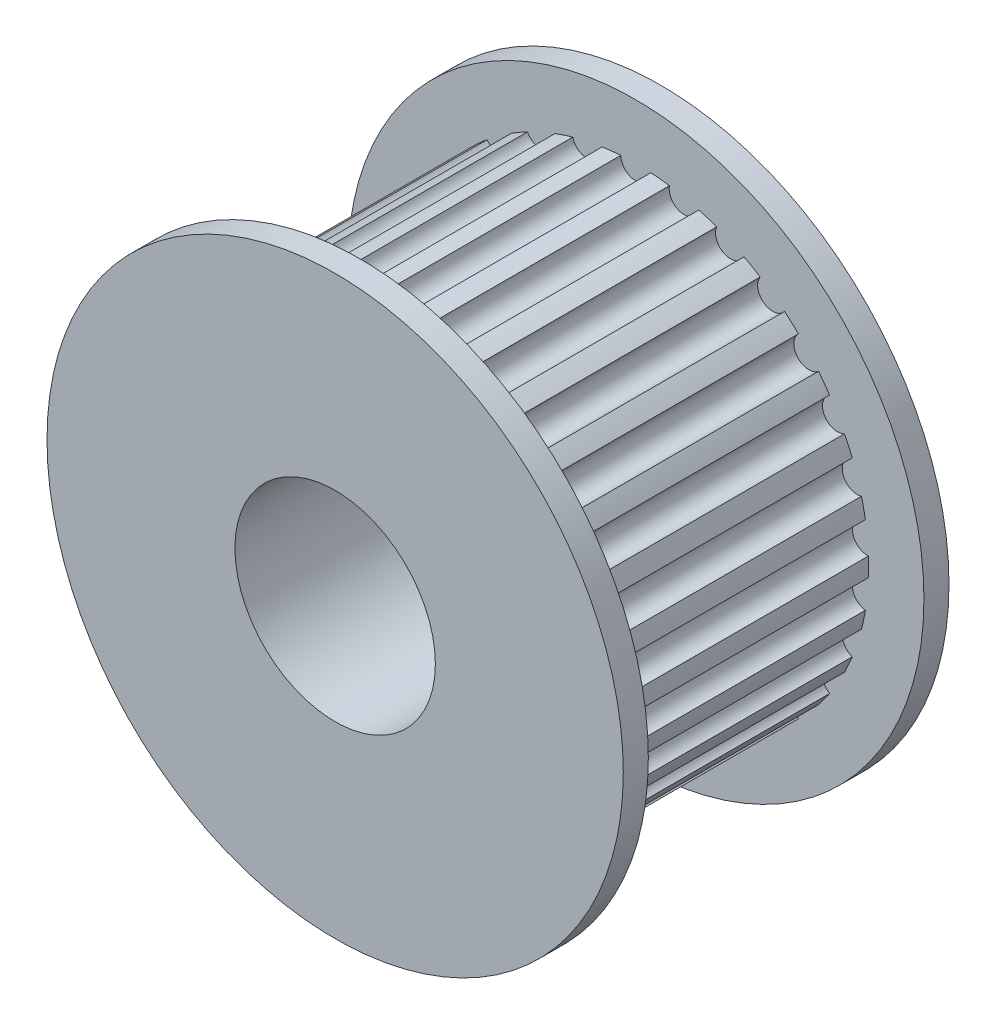
from build123d import *

# Parameters (mm, degrees)
SKETCH_1_R               = 11.5
EXTRUDE_1_DEPTH          = 0.5
SKETCH_2_R               = 9.295
EXTRUDE_2_DEPTH          = 11
CUT_EXTRUDE_3_DEPTH      = 11
SKETCH_3_R               = 11.5
EXTRUDE_3_DEPTH          = 1
SKETCH_6_R               = 4
CUT_EXTRUDE_2_DEPTH      = 1
CUT_EXTRUDE_2_DEPTH_BACK = 14
PATTERN_CIRCULAR_2_COUNT = 30


with BuildPart() as part:
    # 草圖1 → 填料-伸長1 (new body, symmetric)
    with BuildSketch(Plane.XY):
        Circle(SKETCH_1_R)
    extrude(amount=EXTRUDE_1_DEPTH, both=True)

    # 草圖2 → 填料-伸長2 (add)
    with BuildSketch(Plane.XY.offset(0.5)):
        Circle(SKETCH_2_R)
    extrude(amount=EXTRUDE_2_DEPTH)

    # 草圖7 → 除料-伸長3 (cut)
    with BuildSketch(Plane.XY.offset(11.5)):
        with BuildLine():
            ThreePointArc((-0.599687408, 9.27563475), (0, 8.695), (0.599687408, 9.27563475))
            ThreePointArc((0.599687408, 9.27563475), (0, 9.295), (-0.599687408, 9.27563475))
        make_face()
    cut_extrude_3 = extrude(amount=-CUT_EXTRUDE_3_DEPTH, mode=Mode.SUBTRACT)

    # 草圖3 → 填料-伸長3 (add)
    with BuildSketch(Plane.XY.offset(11.5)):
        Circle(SKETCH_3_R)
    extrude(amount=EXTRUDE_3_DEPTH)

    # 草圖6 → 除料-伸長2 (cut, two sides)
    with BuildSketch(Plane(origin=(0, 0, -0.5), x_dir=(-1, 0, 0), z_dir=(0, 0, -1))) as cut_extrude_2_sk:
        Circle(SKETCH_6_R)
    extrude(amount=CUT_EXTRUDE_2_DEPTH, mode=Mode.SUBTRACT)
    extrude(cut_extrude_2_sk.sketch, amount=-CUT_EXTRUDE_2_DEPTH_BACK, mode=Mode.SUBTRACT)

    # 環狀複製排列2: 除料-伸長3 ×30 about axis
    pattern_circular_2_axis = Axis((0, 0, 0), (0, 0, 1))
    for i in range(1, PATTERN_CIRCULAR_2_COUNT):
        add(cut_extrude_3.rotate(pattern_circular_2_axis, i * 360 / PATTERN_CIRCULAR_2_COUNT), mode=Mode.SUBTRACT)


solid = part.part
